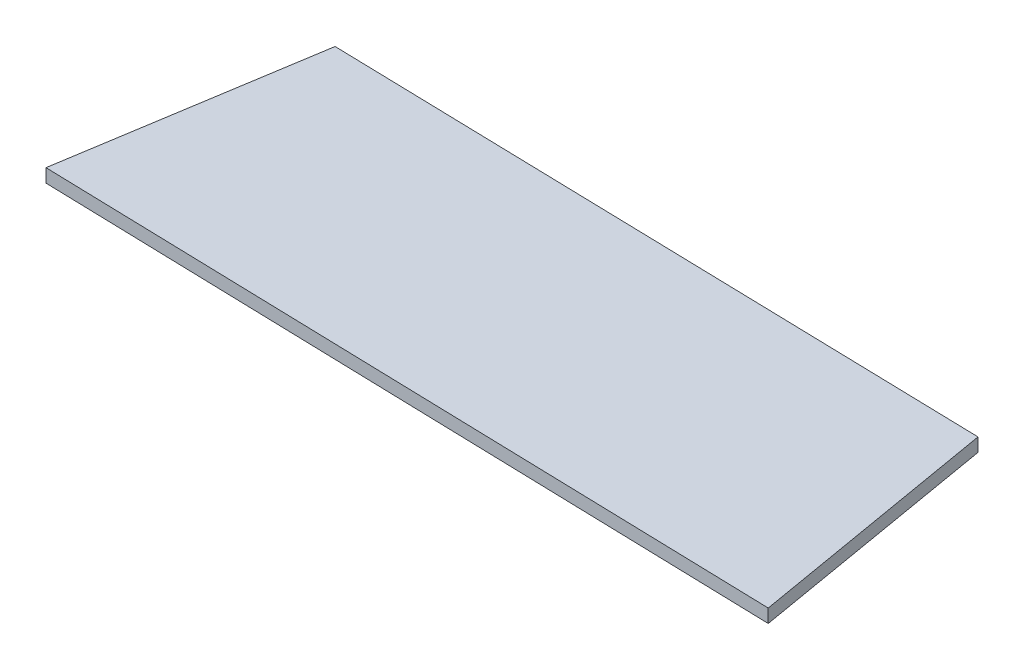
from build123d import *

# Parameters (mm, degrees)
BOSS_EXTRU_1_DEPTH = 2


with BuildPart() as part:
    # Esquisse1 → Boss.-Extru.1 (new body)
    with BuildSketch(Plane(origin=(0, 0, 0), x_dir=(1, 0, 0), z_dir=(0, 1, 0))):
        Polygon((5.910257277, 37.202090876), (0, 0), (110.717432038, -3.020747875), (104.260718726, 34.71544382), align=None)
    extrude(amount=BOSS_EXTRU_1_DEPTH)


solid = part.part
